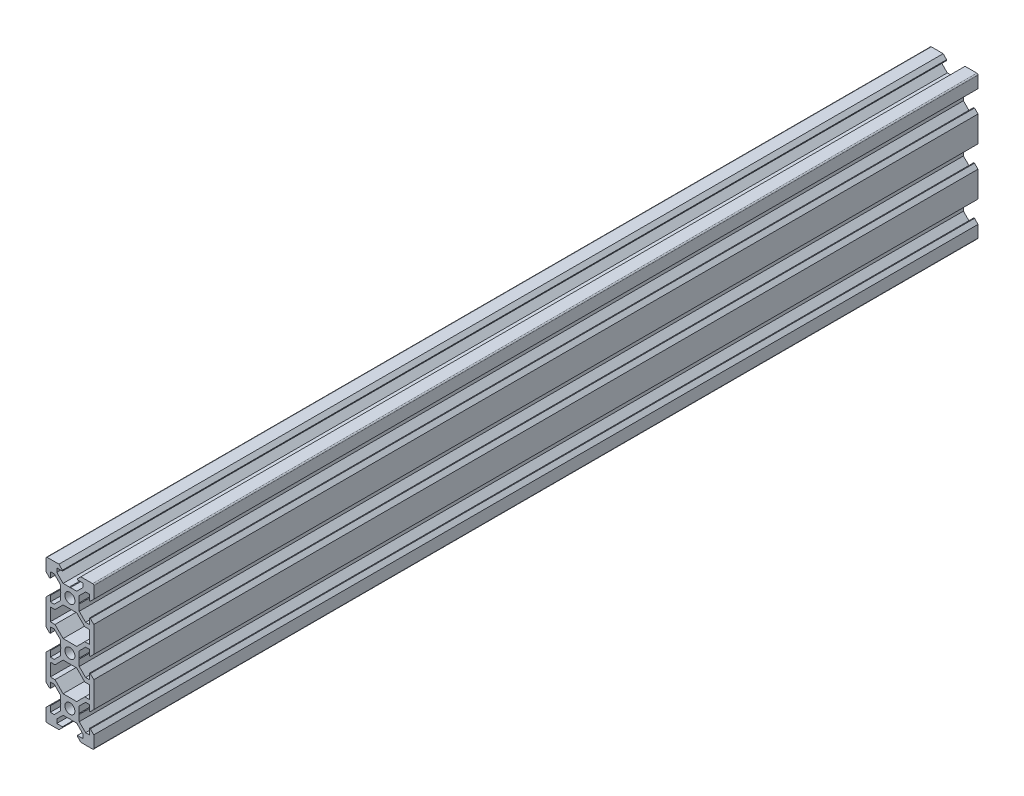
from build123d import *

# Parameters (mm, degrees)
SKETCH1_R           = 2.1
BOSS_EXTRUDE1_DEPTH = 370


with BuildPart() as part:
    # Sketch1 → Boss-Extrude1 (new body)
    with BuildSketch(Plane.XY):
        with BuildLine():
            Line((4.58, -30), (9.5, -30))
            ThreePointArc((9.5, -30), (9.853553391, -29.853553391), (10, -29.5))
            Line((10, -29.5), (10, -24.58))
            Line((10, -24.58), (8.545, -23.125))
            Line((8.545, -23.125), (8.2, -23.125))
            Line((8.2, -23.125), (8.2, -25.5))
            Line((8.2, -25.5), (6.560660172, -25.5))
            Line((6.560660172, -25.5), (3.9, -22.839339828))
            Line((3.9, -22.839339828), (3.9, -20.21))
            Line((3.9, -20.21), (3.69, -20))
            Line((3.69, -20), (3.9, -19.79))
            Line((3.9, -19.79), (3.9, -17.160660172))
            Line((3.9, -17.160660172), (6.560660172, -14.5))
            Line((6.560660172, -14.5), (8.2, -14.5))
            Line((8.2, -14.5), (8.2, -16.875))
            Line((8.2, -16.875), (8.545, -16.875))
            Line((8.545, -16.875), (10, -15.42))
            Line((10, -15.42), (10, -4.58))
            Line((10, -4.58), (8.545, -3.125))
            Line((8.545, -3.125), (8.2, -3.125))
            Line((8.2, -3.125), (8.2, -5.5))
            Line((8.2, -5.5), (6.560660172, -5.5))
            Line((6.560660172, -5.5), (3.9, -2.839339828))
            Line((3.9, -2.839339828), (3.9, -0.21))
            Line((3.9, -0.21), (3.69, 0))
            Line((3.69, 0), (3.9, 0.21))
            Line((3.9, 0.21), (3.9, 2.839339828))
            Line((3.9, 2.839339828), (6.560660172, 5.5))
            Line((6.560660172, 5.5), (8.2, 5.5))
            Line((8.2, 5.5), (8.2, 3.125))
            Line((8.2, 3.125), (8.545, 3.125))
            Line((8.545, 3.125), (10, 4.58))
            Line((10, 4.58), (10, 15.42))
            Line((10, 15.42), (8.545, 16.875))
            Line((8.545, 16.875), (8.2, 16.875))
            Line((8.2, 16.875), (8.2, 14.5))
            Line((8.2, 14.5), (6.560660172, 14.5))
            Line((6.560660172, 14.5), (3.9, 17.160660172))
            Line((3.9, 17.160660172), (3.9, 19.79))
            Line((3.9, 19.79), (3.69, 20))
            Line((3.69, 20), (3.9, 20.21))
            Line((3.9, 20.21), (3.9, 22.839339828))
            Line((3.9, 22.839339828), (6.560660172, 25.5))
            Line((6.560660172, 25.5), (8.2, 25.5))
            Line((8.2, 25.5), (8.2, 23.125))
            Line((8.2, 23.125), (8.545, 23.125))
            Line((8.545, 23.125), (10, 24.58))
            Line((10, 24.58), (10, 29.5))
            ThreePointArc((10, 29.5), (9.853553391, 29.853553391), (9.5, 30))
            Line((9.5, 30), (4.58, 30))
            Line((4.58, 30), (3.125, 28.545))
            Line((3.125, 28.545), (3.125, 28.2))
            Line((3.125, 28.2), (5.5, 28.2))
            Line((5.5, 28.2), (5.5, 26.560660172))
            Line((5.5, 26.560660172), (2.839339828, 23.9))
            Line((2.839339828, 23.9), (0.21, 23.9))
            Line((0.21, 23.9), (0, 23.69))
            Line((0, 23.69), (-0.21, 23.9))
            Line((-0.21, 23.9), (-2.839339828, 23.9))
            Line((-2.839339828, 23.9), (-5.5, 26.560660172))
            Line((-5.5, 26.560660172), (-5.5, 28.2))
            Line((-5.5, 28.2), (-3.125, 28.2))
            Line((-3.125, 28.2), (-3.125, 28.545))
            Line((-3.125, 28.545), (-4.58, 30))
            Line((-4.58, 30), (-9.5, 30))
            ThreePointArc((-9.5, 30), (-9.853553391, 29.853553391), (-10, 29.5))
            Line((-10, 29.5), (-10, 24.58))
            Line((-10, 24.58), (-8.545, 23.125))
            Line((-8.545, 23.125), (-8.2, 23.125))
            Line((-8.2, 23.125), (-8.2, 25.5))
            Line((-8.2, 25.5), (-6.560660172, 25.5))
            Line((-6.560660172, 25.5), (-3.9, 22.839339828))
            Line((-3.9, 22.839339828), (-3.9, 20.21))
            Line((-3.9, 20.21), (-3.69, 20))
            Line((-3.69, 20), (-3.9, 19.79))
            Line((-3.9, 19.79), (-3.9, 17.160660172))
            Line((-3.9, 17.160660172), (-6.560660172, 14.5))
            Line((-6.560660172, 14.5), (-8.2, 14.5))
            Line((-8.2, 14.5), (-8.2, 16.875))
            Line((-8.2, 16.875), (-8.545, 16.875))
            Line((-8.545, 16.875), (-10, 15.42))
            Line((-10, 15.42), (-10, 4.58))
            Line((-10, 4.58), (-8.545, 3.125))
            Line((-8.545, 3.125), (-8.2, 3.125))
            Line((-8.2, 3.125), (-8.2, 5.5))
            Line((-8.2, 5.5), (-6.560660172, 5.5))
            Line((-6.560660172, 5.5), (-3.9, 2.839339828))
            Line((-3.9, 2.839339828), (-3.9, 0.21))
            Line((-3.9, 0.21), (-3.69, 0))
            Line((-3.69, 0), (-3.9, -0.21))
            Line((-3.9, -0.21), (-3.9, -2.839339828))
            Line((-3.9, -2.839339828), (-6.560660172, -5.5))
            Line((-6.560660172, -5.5), (-8.2, -5.5))
            Line((-8.2, -5.5), (-8.2, -3.125))
            Line((-8.2, -3.125), (-8.545, -3.125))
            Line((-8.545, -3.125), (-10, -4.58))
            Line((-10, -4.58), (-10, -15.42))
            Line((-10, -15.42), (-8.545, -16.875))
            Line((-8.545, -16.875), (-8.2, -16.875))
            Line((-8.2, -16.875), (-8.2, -14.5))
            Line((-8.2, -14.5), (-6.560660172, -14.5))
            Line((-6.560660172, -14.5), (-3.9, -17.160660172))
            Line((-3.9, -17.160660172), (-3.9, -19.79))
            Line((-3.9, -19.79), (-3.69, -20))
            Line((-3.69, -20), (-3.9, -20.21))
            Line((-3.9, -20.21), (-3.9, -22.839339828))
            Line((-3.9, -22.839339828), (-6.560660172, -25.5))
            Line((-6.560660172, -25.5), (-8.2, -25.5))
            Line((-8.2, -25.5), (-8.2, -23.125))
            Line((-8.2, -23.125), (-8.545, -23.125))
            Line((-8.545, -23.125), (-10, -24.58))
            Line((-10, -24.58), (-10, -29.5))
            ThreePointArc((-10, -29.5), (-9.853553391, -29.853553391), (-9.5, -30))
            Line((-9.5, -30), (-4.58, -30))
            Line((-4.58, -30), (-3.125, -28.545))
            Line((-3.125, -28.545), (-3.125, -28.2))
            Line((-3.125, -28.2), (-5.5, -28.2))
            Line((-5.5, -28.2), (-5.5, -26.560660172))
            Line((-5.5, -26.560660172), (-2.839339828, -23.9))
            Line((-2.839339828, -23.9), (-0.21, -23.9))
            Line((-0.21, -23.9), (0, -23.69))
            Line((0, -23.69), (0.21, -23.9))
            Line((0.21, -23.9), (2.839339828, -23.9))
            Line((2.839339828, -23.9), (5.5, -26.560660172))
            Line((5.5, -26.560660172), (5.5, -28.2))
            Line((5.5, -28.2), (3.125, -28.2))
            Line((3.125, -28.2), (3.125, -28.545))
            Line((3.125, -28.545), (4.58, -30))
        make_face()
        with Locations((0, -20)):
            Circle(SKETCH1_R, mode=Mode.SUBTRACT)
        Polygon((-6.239339828, -12.7), (-8.2, -12.7), (-8.2, -7.3), (-6.239339828, -7.3), (-2.839339828, -3.9), (2.839339828, -3.9), (6.239339828, -7.3), (8.2, -7.3), (8.2, -12.7), (6.239339828, -12.7), (2.839339828, -16.1), (-2.839339828, -16.1), align=None, mode=Mode.SUBTRACT)
        Polygon((-6.239339828, 7.3), (-8.2, 7.3), (-8.2, 12.7), (-6.239339828, 12.7), (-2.839339828, 16.1), (2.839339828, 16.1), (6.239339828, 12.7), (8.2, 12.7), (8.2, 7.3), (6.239339828, 7.3), (2.839339828, 3.9), (-2.839339828, 3.9), align=None, mode=Mode.SUBTRACT)
        with Locations((0, 20)):
            Circle(SKETCH1_R, mode=Mode.SUBTRACT)
        Circle(SKETCH1_R, mode=Mode.SUBTRACT)
    extrude(amount=BOSS_EXTRUDE1_DEPTH)


solid = part.part
